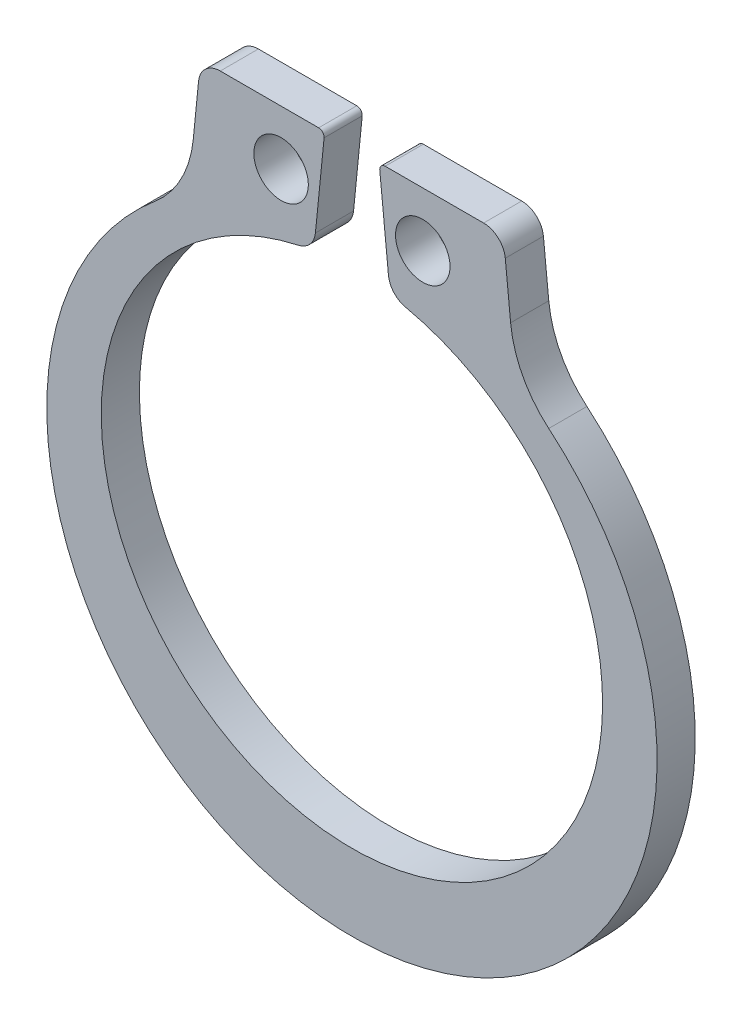
from build123d import *

# Parameters (mm, degrees)
SKETCH1_R           = 0.635
BOSS_EXTRUDE1_DEPTH = 0.889


with BuildPart() as part:
    # Sketch1 → Boss-Extrude1 (new body)
    with BuildSketch(Plane.XY):
        with BuildLine():
            Line((-3.698228745, 6.615080486), (-3.574085754, 7.856510393))
            ThreePointArc((-3.574085754, 7.856510393), (-3.409477564, 8.182620391), (-3.068606861, 8.313962504))
            Line((-3.068606861, 8.313962504), (-0.77533342, 8.313962504))
            ThreePointArc((-0.77533342, 8.313962504), (-0.681168949, 8.27218018), (-0.648963697, 8.174325532))
            Line((-0.648963697, 8.174325532), (-0.851111104, 6.152851468))
            ThreePointArc((-0.851111104, 6.152851468), (-0.97722427, 5.865544883), (-1.248062797, 5.707127408))
            ThreePointArc((-1.248062797, 5.707127408), (0, -5.842), (1.248062797, 5.707127408))
            ThreePointArc((1.248062797, 5.707127408), (0.97722427, 5.865544883), (0.851111104, 6.152851468))
            Line((0.851111104, 6.152851468), (0.648963697, 8.174325532))
            ThreePointArc((0.648963697, 8.174325532), (0.681168949, 8.27218018), (0.77533342, 8.313962504))
            Line((0.77533342, 8.313962504), (3.068606861, 8.313962504))
            ThreePointArc((3.068606861, 8.313962504), (3.409477564, 8.182620391), (3.574085754, 7.856510393))
            Line((3.574085754, 7.856510393), (3.698228745, 6.615080486))
            ThreePointArc((3.698228745, 6.615080486), (3.978211686, 5.684290697), (4.587301311, 4.926814687))
            ThreePointArc((4.587301311, 4.926814687), (0, -7.62), (-4.587301311, 4.926814687))
            ThreePointArc((-4.587301311, 4.926814687), (-3.978211686, 5.684290697), (-3.698228745, 6.615080486))
        make_face()
        with Locations((-1.651, 7.043962504)):
            Circle(SKETCH1_R, mode=Mode.SUBTRACT)
        with Locations((1.651, 7.043962504)):
            Circle(SKETCH1_R, mode=Mode.SUBTRACT)
    extrude(amount=BOSS_EXTRUDE1_DEPTH)


solid = part.part
